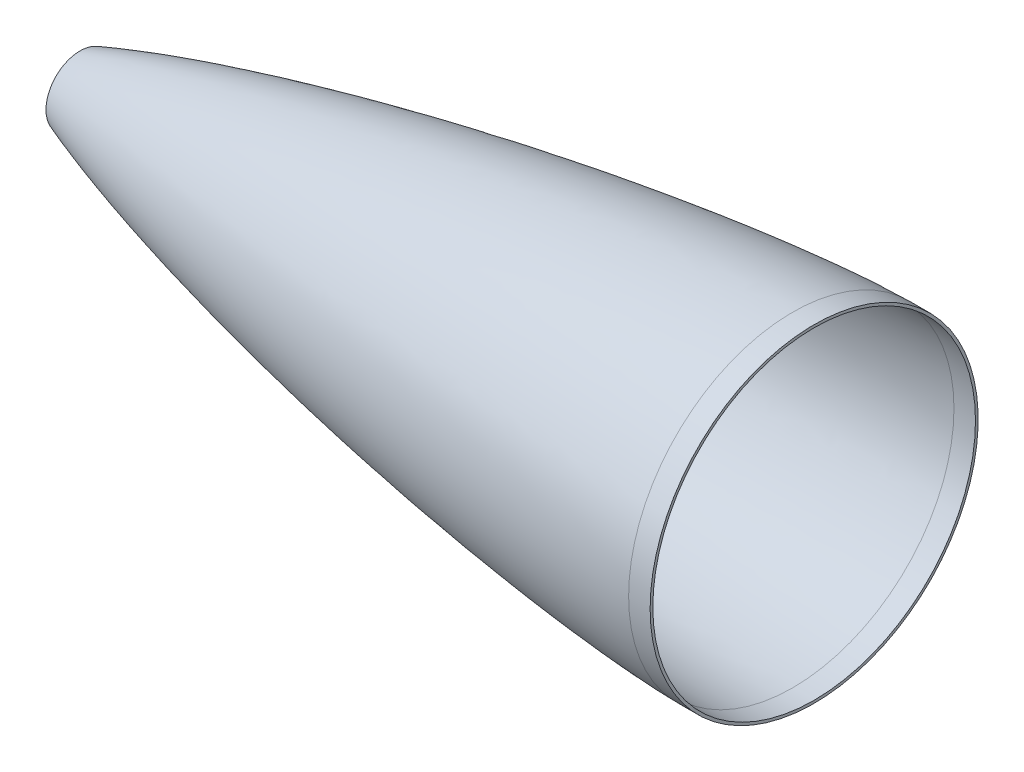
from build123d import *

# Parameters (mm, degrees)
SKETCH2_R          = 96.8375
CUT_EXTRUDE1_DEPTH = 38.1


with BuildPart() as part:
    # Sketch1 → Revolve3 (revolve)
    with BuildSketch(Plane.XY, mode=Mode.PRIVATE) as revolve3_sk:
        with BuildLine():
            Line((457.2, 95.25), (469.896281998, 95.25))
            Line((469.896281998, 95.25), (469.896281998, 96.8375))
            Line((469.896281998, 96.8375), (457.196281998, 96.8375))
            add(Edge.make_bspline(
                [(-1.613027701, 0), (-1.612711878, 0.00175474), (-1.605563851, 0.041446569), (-1.594988186, 0.100149739), (-1.581389731, 0.175782501), (-1.572707122, 0.223728678), (-1.566997167, 0.255936942), (-1.563638571, 0.273894792), (-1.562530166, 0.281172056), (-1.54113805, 0.391845853), (-1.506748162, 0.514869843), (-1.441006297, 0.695544345), (-1.388645233, 0.806113014), (-1.305801045, 0.968259164), (-1.213168713, 1.120857252), (-1.072817399, 1.329577523), (-0.905983242, 1.546851815), (-0.710549212, 1.776732498), (-0.51743848, 1.986597944), (-0.260869397, 2.248696572), (0.059240882, 2.551506213), (0.444273305, 2.889775507), (0.960794747, 3.31752069), (1.611107989, 3.817847959), (2.399945553, 4.382869642), (3.459963218, 5.09973513), (4.800955867, 5.94461061), (6.97048626, 7.218451099), (9.720437652, 8.702577269), (13.059488776, 10.368335632), (17.554227076, 12.474552049), (23.231330402, 14.936988035), (30.109282575, 17.703427282), (37.034664222, 20.324531793), (43.998739715, 22.827822111), (53.325878023, 26.031673422), (65.048289722, 29.824948589), (79.192461596, 34.109751932), (93.397633025, 38.171640178), (107.653121858, 42.042021616), (121.951053653, 45.743284615), (141.064458448, 50.474273797), (165.03776907, 56.037803904), (193.911776008, 62.2236635), (222.876667343, 67.959465053), (251.92166464, 73.268981195), (281.039554234, 78.161617777), (310.225321028, 82.634691682), (339.475870497, 86.672057689), (368.790008375, 90.240078055), (393.271656318, 92.773167666), (412.891914508, 94.477240181), (427.624405065, 95.565697791), (439.924064117, 96.284968563), (449.769524012, 96.687456769), (454.72263814, 96.825913148), (457.196281998, 96.8375)],
                knots=[-0.000606109, -0.000606109, -0.000606109, -0.000606109, -0.000594771, -0.000349645, -0.000227082, -0.00010452, -4.3238e-05, -1.2597e-05, 2.723e-06, 1.8043e-05, 7.9325e-05, 0.000140606, 0.000263169, 0.000385732, 0.000630857, 0.000875983, 0.001366234, 0.001856485, 0.002346736, 0.002836988, 0.00381749, 0.004797992, 0.005778495, 0.0077395, 0.009700504, 0.011661509, 0.015583519, 0.019505528, 0.027349547, 0.035193566, 0.043037585, 0.058725623, 0.074413661, 0.090101699, 0.105789738, 0.121477776, 0.152853852, 0.184229928, 0.215606004, 0.24698208, 0.278358156, 0.309734233, 0.372486385, 0.435238537, 0.49799069, 0.560742842, 0.623494994, 0.686247146, 0.748999299, 0.811751451, 0.874503603, 0.90587968, 0.937255756, 0.968631832, 0.98431987, 1.000007908, 1.000007908, 1.000007908, 1.000007908], degree=3))
            Line((-1.613027701, 0), (0, 0))
            add(Edge.make_bspline(
                [(0, 0), (0.002261413, 0.012559634), (0.008229149, 0.03727132), (0.026197477, 0.085010802), (0.070593088, 0.176725307), (0.135390602, 0.284235785), (0.220401303, 0.406590084), (0.336037993, 0.556544126), (0.508304998, 0.760811711), (0.80208614, 1.073293742), (1.325080854, 1.565169332), (2.238118633, 2.319225256), (3.825271995, 3.466618443), (6.613989832, 5.225294798), (11.456120137, 7.876617711), (19.293604572, 11.601746405), (32.615554098, 17.130480015), (51.688271319, 23.981890995), (75.613057969, 31.54621241), (103.310212008, 39.361975261), (131.892371678, 46.686426538), (160.614305524, 53.440297164), (189.44815344, 59.696867207), (218.376688059, 65.499444524), (247.387631707, 70.874021631), (276.472706829, 75.831796355), (305.625866717, 80.372187528), (334.843049411, 84.481216859), (364.121565724, 88.129371268), (389.792768776, 90.870557363), (411.834102605, 92.837355417), (428.995077346, 94.067568174), (440.032338735, 94.69756489), (448.618051981, 95.062046142), (453.521410507, 95.200160943), (455.973700484, 95.244255862), (457.2, 95.25)],
                knots=[0, 0, 0, 0, 0, 0.000108244, 0.000216487, 0.000432974, 0.000865949, 0.001174715, 0.001483481, 0.002043604, 0.003138685, 0.004821522, 0.007588035, 0.012111566, 0.019790706, 0.032854349, 0.05452956, 0.085906528, 0.142462243, 0.205216412, 0.267970588, 0.330724763, 0.393478942, 0.456233118, 0.518987298, 0.581741474, 0.644495652, 0.707249831, 0.770004011, 0.832758189, 0.895512367, 0.926889456, 0.958266545, 0.979133273, 0.989566636, 1, 1, 1, 1, 1], degree=4))
        make_face()
    revolve(revolve3_sk.sketch.rotate(Axis((0, 0, 0), (1, 0, 0)), 90), axis=Axis((0, 0, 0), (1, 0, 0)))

    # Sketch2 → Cut-Extrude1 (cut)
    with BuildSketch(Plane(origin=(-1.613027875, 0, 0), x_dir=(0, 0, -1), z_dir=(1, 0, 0))):
        with Locations(Location((0, 0, 0), (0, 0, 180))):
            Circle(SKETCH2_R)
    extrude(amount=CUT_EXTRUDE1_DEPTH, mode=Mode.SUBTRACT)


solid = part.part
